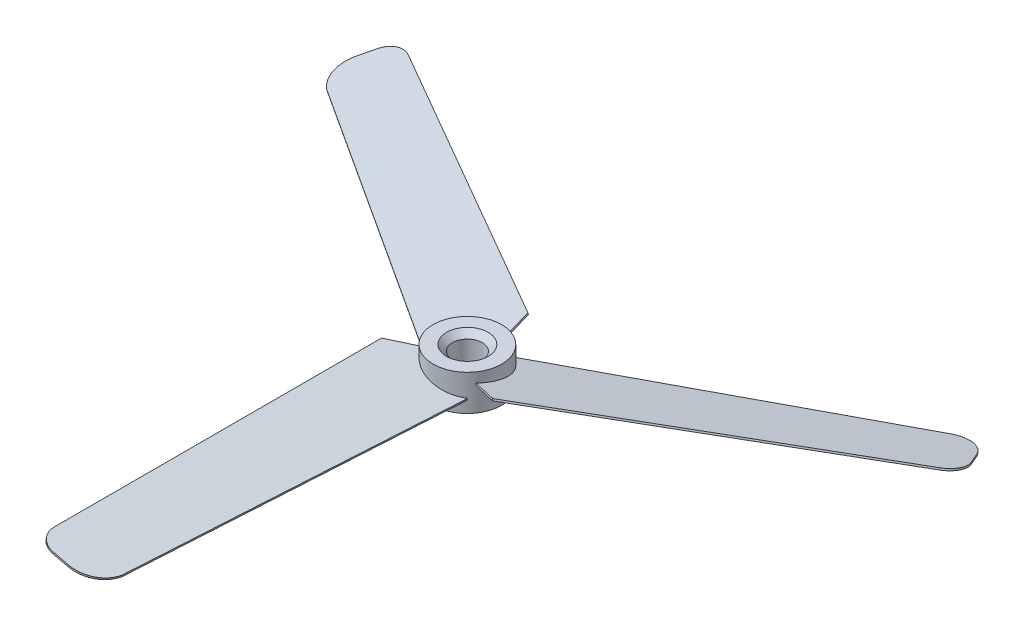
from build123d import *

# Parameters (mm, degrees)
SKETCH2_R           = 5.75
BOSS_EXTRUDE3_DEPTH = 3
BOSS_EXTRUDE4_DEPTH = 0.15
SKETCH10_R          = 2.5
CUT_EXTRUDE2_DEPTH  = 7
CIRPATTERN1_COUNT   = 3
CHAMFER1_SIZE       = 1


with BuildPart() as part:
    # Sketch2 → Boss-Extrude3 (new body, symmetric)
    with BuildSketch(Plane(origin=(0, 0, 0), x_dir=(1, 0, 0), z_dir=(0, 1, 0))):
        Circle(SKETCH2_R)
    extrude(amount=BOSS_EXTRUDE3_DEPTH, both=True)

    # Sketch7 → Boss-Extrude4 (add, symmetric)
    with BuildSketch(Plane(origin=(0, 0, 0), x_dir=(0.974370065, -0.224951054, 0), z_dir=(-0.224951054, -0.974370065, 0))):
        with BuildLine():
            Line((-4.618684487, 1.883456295), (-9.181754015, 5.498179334))
            Line((-9.181754015, 5.498179334), (-9.181754015, 60.5))
            ThreePointArc((-9.181754015, 60.5), (-8.303074359, 62.621320344), (-6.181754015, 63.5))
            Line((-6.181754015, 63.5), (-3.529096808, 63.5))
            ThreePointArc((-3.529096808, 63.5), (-0.299288732, 62.316849459), (1.401979675, 59.327335916))
            add(Edge.make_bspline(
                [(1.401979675, 59.327335916), (4.254001787, 2.228053108)],
                knots=[0, 0, 1, 1], degree=1))
            add(Edge.make_bspline(
                [(-4.618684487, 1.883456295), (-0.212236613, 8.938890212), (4.254001787, 2.228053108)],
                knots=[0, 0, 0, 1, 1, 1], degree=2))
        make_face()
    boss_extrude4 = extrude(amount=BOSS_EXTRUDE4_DEPTH, both=True)

    # Sketch10 → Cut-Extrude2 (cut, through all)
    with BuildSketch(Plane.XZ.offset(3)):
        Circle(SKETCH10_R)
    extrude(amount=-CUT_EXTRUDE2_DEPTH, mode=Mode.SUBTRACT)

    # CirPattern1: Boss-Extrude4 ×3 about axis
    cirpattern1_axis = Axis((0, 0, 0), (0, 1, 0))
    for i in range(1, CIRPATTERN1_COUNT):
        add(boss_extrude4.rotate(cirpattern1_axis, i * 360 / CIRPATTERN1_COUNT))

    # Chamfer1
    chamfer1_edges = [part.edges().sort_by_distance(p)[0] for p in [
        (-2.5, 3, 0),
        (-2.5, -3, 0),
    ]]
    chamfer(chamfer1_edges, length=CHAMFER1_SIZE)


solid = part.part
